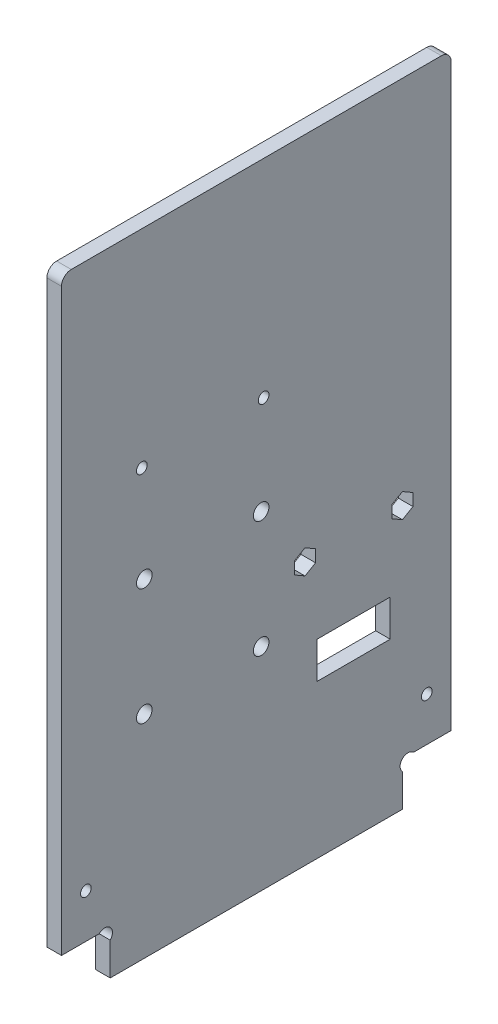
from build123d import *

# Parameters (mm, degrees)
EXTRUSION1_DEPTH        = 3
ESQUISSE2_R             = 1.6
ESQUISSE2_R_2           = 1.1
ENL_V_MAT_EXTRU_1_DEPTH = 4
ESQUISSE3_W             = 15
ESQUISSE3_H             = 7.5
ENL_V_MAT_EXTRU_2_DEPTH = 4
ESQUISSE4_R             = 1.1
ENL_V_MAT_EXTRU_3_DEPTH = 4
ENL_V_MAT_EXTRU_4_DEPTH = 4
CONG_1_R                = 2
ESQUISSE6_R             = 1.1
ENL_V_MAT_EXTRU_5_DEPTH = 4


with BuildPart() as part:
    # Esquisse1 → Extrusion1 (new body)
    with BuildSketch(Plane(origin=(0, 0, 0), x_dir=(0, 0, -1), z_dir=(1, 0, 0))):
        with BuildLine():
            Line((10, 6.7372583), (10, 0))
            Line((10, 0), (70, 0))
            Line((70, 0), (70, 6.7372583))
            ThreePointArc((70, 6.7372583), (70, 9), (72.2627417, 9))
            Line((72.2627417, 9), (80, 9))
            Line((80, 9), (80, 130))
            Line((80, 130), (0, 130))
            Line((0, 130), (0, 9))
            Line((0, 9), (7.7372583, 9))
            ThreePointArc((7.7372583, 9), (10, 9), (10, 6.7372583))
        make_face()
    extrude(amount=EXTRUSION1_DEPTH)

    # Esquisse2 → Enlèv. mat.-Extru.1 (cut, through all)
    with BuildSketch(Plane(origin=(3, 0, 0), x_dir=(0, 0, -1), z_dir=(1, 0, 0))):
        with Locations((17, 67.45)):
            Circle(ESQUISSE2_R)
        with Locations((17, 43.45)):
            Circle(ESQUISSE2_R)
        with Locations((41, 43.45)):
            Circle(ESQUISSE2_R)
        with Locations((41, 67.45)):
            Circle(ESQUISSE2_R)
        with Locations((70, 54)):
            Circle(ESQUISSE2_R_2)
        with Locations((50, 54)):
            Circle(ESQUISSE2_R_2)
    extrude(amount=-ENL_V_MAT_EXTRU_1_DEPTH, mode=Mode.SUBTRACT)

    # Esquisse3 → Enlèv. mat.-Extru.2 (cut, through all)
    with BuildSketch(Plane.ZY):
        with Locations((-60, 35.25)):
            Rectangle(ESQUISSE3_W, ESQUISSE3_H)
    extrude(amount=-ENL_V_MAT_EXTRU_2_DEPTH, mode=Mode.SUBTRACT)

    # Esquisse4 → Enlèv. mat.-Extru.3 (cut, through all)
    with BuildSketch(Plane(origin=(3, 0, 0), x_dir=(0, 0, -1), z_dir=(1, 0, 0))):
        with Locations((75, 18)):
            Circle(ESQUISSE4_R)
        with Locations((5, 18)):
            Circle(ESQUISSE4_R)
    extrude(amount=-ENL_V_MAT_EXTRU_3_DEPTH, mode=Mode.SUBTRACT)

    # Esquisse5 → Enlèv. mat.-Extru.4 (cut, through all)
    with BuildSketch(Plane(origin=(3, 0, 0), x_dir=(0, 0, -1), z_dir=(1, 0, 0))):
        Polygon((50, 51.5), (52.165063509, 52.75), (52.165063509, 55.25), (50, 56.5), (47.834936491, 55.25), (47.834936491, 52.75), align=None)
        Polygon((70, 51.5), (72.165063509, 52.75), (72.165063509, 55.25), (70, 56.5), (67.834936491, 55.25), (67.834936491, 52.75), align=None)
    extrude(amount=-ENL_V_MAT_EXTRU_4_DEPTH, mode=Mode.SUBTRACT)

    # Congé1
    cong_1_edges = [part.edges().sort_by_distance(p)[0] for p in [
        (1.5, 130, 0),
        (1.5, 130, -80),
    ]]
    fillet(cong_1_edges, radius=CONG_1_R)

    # Esquisse6 → Enlèv. mat.-Extru.5 (cut, through all)
    with BuildSketch(Plane(origin=(3, 0, 0), x_dir=(0, 0, -1), z_dir=(1, 0, 0))):
        with Locations((16.5, 87.45)):
            Circle(ESQUISSE6_R)
        with Locations((41.5, 87.45)):
            Circle(ESQUISSE6_R)
    extrude(amount=-ENL_V_MAT_EXTRU_5_DEPTH, mode=Mode.SUBTRACT)


solid = part.part
